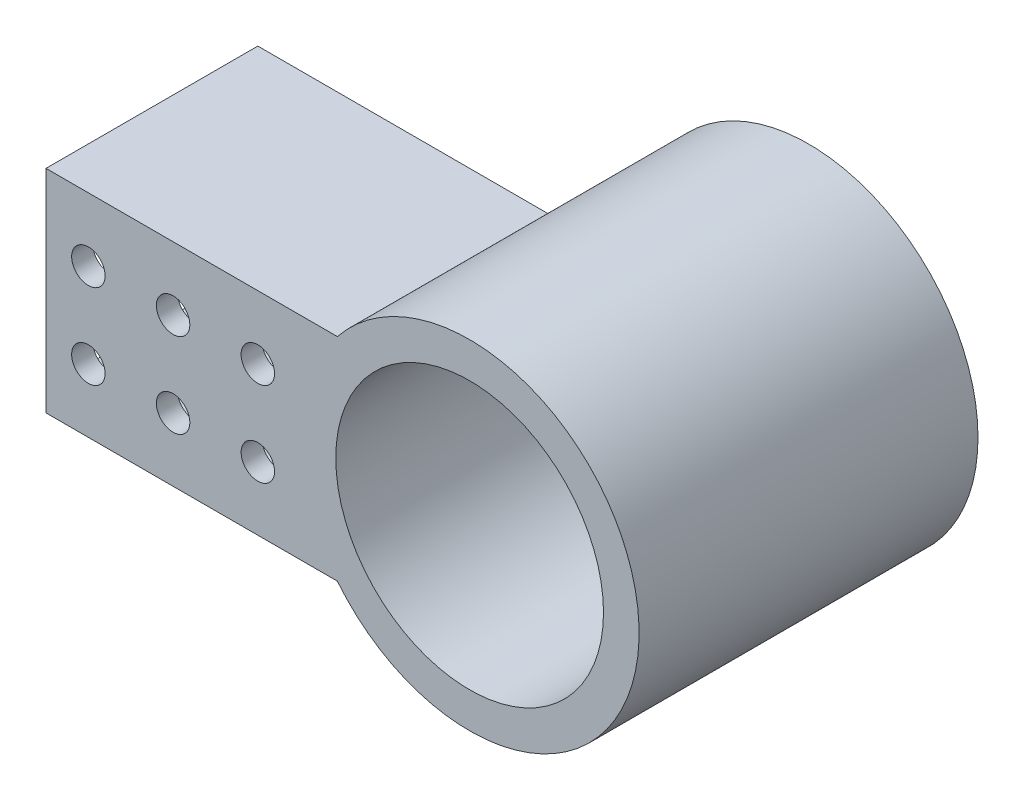
from build123d import *

# Parameters (mm, degrees)
SKETCH1_R           = 25.4
SKETCH1_R_2         = 20.066
BOSS_EXTRUDE1_DEPTH = 50.8
BOSS_EXTRUDE2_DEPTH = 31.75
SKETCH3_W           = 25.4
SKETCH3_H           = 25.4
CUT_EXTRUDE1_DEPTH  = 38.1
SKETCH4_R           = 2.50825
CUT_EXTRUDE2_DEPTH  = 31.75
LPATTERN1_COUNT     = 3
LPATTERN1_PITCH     = 12.7


with BuildPart() as part:
    # Sketch1 → Boss-Extrude1 (new body)
    with BuildSketch(Plane.XY):
        Circle(SKETCH1_R)
        Circle(SKETCH1_R_2, mode=Mode.SUBTRACT)
    extrude(amount=BOSS_EXTRUDE1_DEPTH)

    # Sketch2 → Boss-Extrude2 (add)
    with BuildSketch(Plane.XY.offset(50.8)):
        with BuildLine():
            Line((-19.827868645, 15.875), (-63.5, 15.875))
            Line((-63.5, 15.875), (-63.5, -15.875))
            Line((-63.5, -15.875), (-19.827868645, -15.875))
            ThreePointArc((-19.827868645, -15.875), (-25.4, 0), (-19.827868645, 15.875))
        make_face()
    extrude(amount=-BOSS_EXTRUDE2_DEPTH)

    # Sketch3 → Cut-Extrude1 (cut)
    with BuildSketch(Plane.ZY.offset(63.5)):
        with Locations((34.925, 0)):
            Rectangle(SKETCH3_W, SKETCH3_H)
    extrude(amount=-CUT_EXTRUDE1_DEPTH, mode=Mode.SUBTRACT)

    # Sketch4 → Cut-Extrude2 (cut)
    with BuildSketch(Plane.XY.offset(50.8)):
        with Locations((-57.15, 6.35)):
            Circle(SKETCH4_R)
        with Locations((-57.15, -6.35)):
            Circle(SKETCH4_R)
    cut_extrude2 = extrude(amount=-CUT_EXTRUDE2_DEPTH, mode=Mode.SUBTRACT)

    # LPattern1: Cut-Extrude2 ×3
    with Locations(*[(i * LPATTERN1_PITCH, 0, 0) for i in range(1, LPATTERN1_COUNT)]):
        add(cut_extrude2, mode=Mode.SUBTRACT)


solid = part.part
